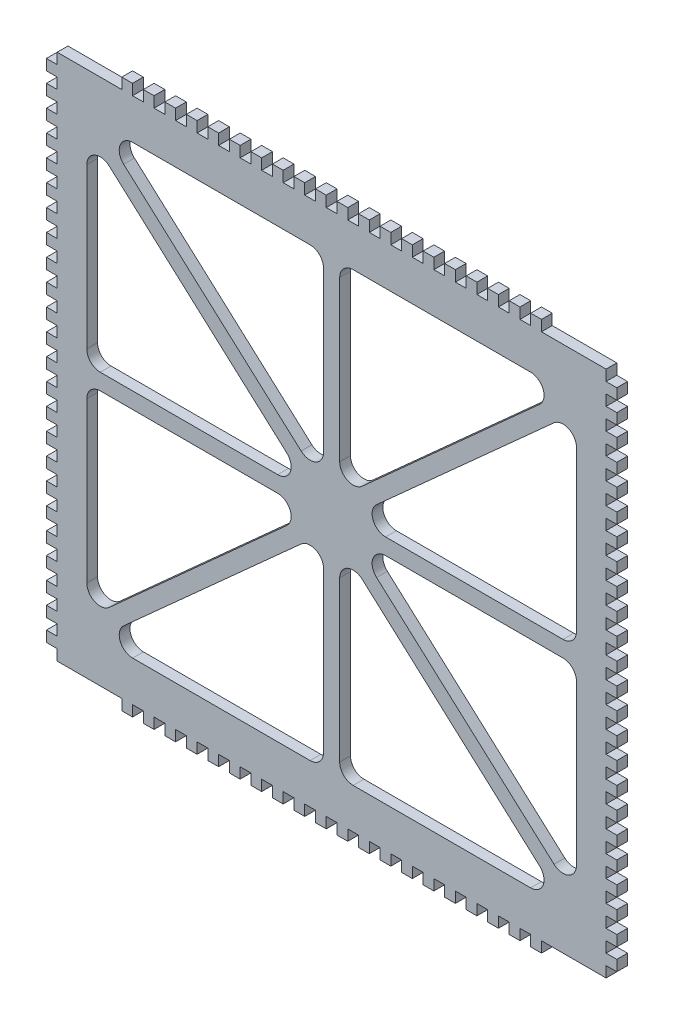
from build123d import *

# Parameters (mm, degrees)
SKETCH1_W           = 212
SKETCH1_H           = 196
BOSS_EXTRUDE1_DEPTH = 4
SKETCH2_W           = 4
SKETCH2_H           = 4
CUT_EXTRUDE1_DEPTH  = 4
SKETCH4_W           = 4
SKETCH4_H           = 4
BOSS_EXTRUDE2_DEPTH = 4


with BuildPart() as part:
    # Sketch1 → Boss-Extrude1 (new body)
    with BuildSketch(Plane.XY):
        Rectangle(SKETCH1_W, SKETCH1_H)
        with BuildLine():
            Line((-73.951477371, 83), (-8, 83))
            ThreePointArc((-8, 83), (-4.464466094, 81.535533906), (-3, 78))
            Line((-3, 78), (-3, 18.682929977))
            ThreePointArc((-3, 18.682929977), (-5.965055791, 14.115764328), (-11.343600827, 14.965359062))
            Line((-11.343600827, 14.965359062), (-77.295078198, 74.282429085))
            ThreePointArc((-77.295078198, 74.282429085), (-78.619874021, 79.790550952), (-73.951477371, 83))
        make_face(mode=Mode.SUBTRACT)
        with BuildLine():
            Line((-82.656399173, 71.034640938), (-16.704921802, 11.717570915))
            ThreePointArc((-16.704921802, 11.717570915), (-15.380125979, 6.209449048), (-20.048522629, 3))
            Line((-20.048522629, 3), (-86, 3))
            ThreePointArc((-86, 3), (-89.535533906, 4.464466094), (-91, 8))
            Line((-91, 8), (-91, 67.317070023))
            ThreePointArc((-91, 67.317070023), (-88.034944209, 71.884235672), (-82.656399173, 71.034640938))
        make_face(mode=Mode.SUBTRACT)
        with BuildLine():
            Line((8, 83), (73.951477371, 83))
            ThreePointArc((73.951477371, 83), (78.619874021, 79.790550952), (77.295078198, 74.282429085))
            Line((77.295078198, 74.282429085), (11.343600827, 14.965359062))
            ThreePointArc((11.343600827, 14.965359062), (5.965055791, 14.115764328), (3, 18.682929977))
            Line((3, 18.682929977), (3, 78))
            ThreePointArc((3, 78), (4.464466094, 81.535533906), (8, 83))
        make_face(mode=Mode.SUBTRACT)
        with BuildLine():
            Line((82.656399173, 71.034640938), (16.704921802, 11.717570915))
            ThreePointArc((16.704921802, 11.717570915), (15.380125979, 6.209449048), (20.048522629, 3))
            Line((20.048522629, 3), (86, 3))
            ThreePointArc((86, 3), (89.535533906, 4.464466094), (91, 8))
            Line((91, 8), (91, 67.317070023))
            ThreePointArc((91, 67.317070023), (88.034944209, 71.884235672), (82.656399173, 71.034640938))
        make_face(mode=Mode.SUBTRACT)
        with BuildLine():
            Line((-91, -8), (-91, -67.317070023))
            ThreePointArc((-91, -67.317070023), (-88.034944209, -71.884235672), (-82.656399173, -71.034640938))
            Line((-82.656399173, -71.034640938), (-16.704921802, -11.717570915))
            ThreePointArc((-16.704921802, -11.717570915), (-15.380125979, -6.209449048), (-20.048522629, -3))
            Line((-20.048522629, -3), (-86, -3))
            ThreePointArc((-86, -3), (-89.535533906, -4.464466094), (-91, -8))
        make_face(mode=Mode.SUBTRACT)
        with BuildLine():
            Line((91, -8), (91, -67.317070023))
            ThreePointArc((91, -67.317070023), (88.034944209, -71.884235672), (82.656399173, -71.034640938))
            Line((82.656399173, -71.034640938), (16.704921802, -11.717570915))
            ThreePointArc((16.704921802, -11.717570915), (15.380125979, -6.209449048), (20.048522629, -3))
            Line((20.048522629, -3), (86, -3))
            ThreePointArc((86, -3), (89.535533906, -4.464466094), (91, -8))
        make_face(mode=Mode.SUBTRACT)
        with BuildLine():
            Line((11.343600827, -14.965359062), (77.295078198, -74.282429085))
            ThreePointArc((77.295078198, -74.282429085), (78.619874021, -79.790550952), (73.951477371, -83))
            Line((73.951477371, -83), (8, -83))
            ThreePointArc((8, -83), (4.464466094, -81.535533906), (3, -78))
            Line((3, -78), (3, -18.682929977))
            ThreePointArc((3, -18.682929977), (5.965055791, -14.115764328), (11.343600827, -14.965359062))
        make_face(mode=Mode.SUBTRACT)
        with BuildLine():
            Line((-3, -18.682929977), (-3, -78))
            ThreePointArc((-3, -78), (-4.464466094, -81.535533906), (-8, -83))
            Line((-8, -83), (-73.951477371, -83))
            ThreePointArc((-73.951477371, -83), (-78.619874021, -79.790550952), (-77.295078198, -74.282429085))
            Line((-77.295078198, -74.282429085), (-11.343600827, -14.965359062))
            ThreePointArc((-11.343600827, -14.965359062), (-5.965055791, -14.115764328), (-3, -18.682929977))
        make_face(mode=Mode.SUBTRACT)
    extrude(amount=BOSS_EXTRUDE1_DEPTH)

    # Sketch2 → Cut-Extrude1 (cut)
    with BuildSketch(Plane.XY.offset(4)):
        with Locations((-104, -48)):
            Rectangle(SKETCH2_W, SKETCH2_H)
        with Locations((-104, 88)):
            Rectangle(SKETCH2_W, SKETCH2_H)
        with Locations((-104, 80)):
            Rectangle(SKETCH2_W, SKETCH2_H)
        with Locations((-104, 72)):
            Rectangle(SKETCH2_W, SKETCH2_H)
        with Locations((-104, 64)):
            Rectangle(SKETCH2_W, SKETCH2_H)
        with Locations((-104, 56)):
            Rectangle(SKETCH2_W, SKETCH2_H)
        with Locations((-104, 48)):
            Rectangle(SKETCH2_W, SKETCH2_H)
        with Locations((-104, 40)):
            Rectangle(SKETCH2_W, SKETCH2_H)
        with Locations((-104, 32)):
            Rectangle(SKETCH2_W, SKETCH2_H)
        with Locations((-104, 24)):
            Rectangle(SKETCH2_W, SKETCH2_H)
        with Locations((-104, 16)):
            Rectangle(SKETCH2_W, SKETCH2_H)
        with Locations((-104, 8)):
            Rectangle(SKETCH2_W, SKETCH2_H)
        with Locations((-104, 0)):
            Rectangle(SKETCH2_W, SKETCH2_H)
        with Locations((-104, -8)):
            Rectangle(SKETCH2_W, SKETCH2_H)
        with Locations((-104, -16)):
            Rectangle(SKETCH2_W, SKETCH2_H)
        with Locations((-104, -24)):
            Rectangle(SKETCH2_W, SKETCH2_H)
        with Locations((-104, -32)):
            Rectangle(SKETCH2_W, SKETCH2_H)
        with Locations((-104, -40)):
            Rectangle(SKETCH2_W, SKETCH2_H)
        with Locations((104, -96)):
            Rectangle(SKETCH2_W, SKETCH2_H)
        with Locations((104, -88)):
            Rectangle(SKETCH2_W, SKETCH2_H)
        with Locations((104, -80)):
            Rectangle(SKETCH2_W, SKETCH2_H)
        with Locations((104, -72)):
            Rectangle(SKETCH2_W, SKETCH2_H)
        with Locations((104, -64)):
            Rectangle(SKETCH2_W, SKETCH2_H)
        with Locations((104, -56)):
            Rectangle(SKETCH2_W, SKETCH2_H)
        with Locations((104, -48)):
            Rectangle(SKETCH2_W, SKETCH2_H)
        with Locations((104, 96)):
            Rectangle(SKETCH2_W, SKETCH2_H)
        with Locations((-104, 96)):
            Rectangle(SKETCH2_W, SKETCH2_H)
        with Locations((104, -40)):
            Rectangle(SKETCH2_W, SKETCH2_H)
        with Locations((104, -32)):
            Rectangle(SKETCH2_W, SKETCH2_H)
        with Locations((104, -24)):
            Rectangle(SKETCH2_W, SKETCH2_H)
        with Locations((104, -16)):
            Rectangle(SKETCH2_W, SKETCH2_H)
        with Locations((104, -8)):
            Rectangle(SKETCH2_W, SKETCH2_H)
        with Locations((104, 0)):
            Rectangle(SKETCH2_W, SKETCH2_H)
        with Locations((104, 8)):
            Rectangle(SKETCH2_W, SKETCH2_H)
        with Locations((104, 16)):
            Rectangle(SKETCH2_W, SKETCH2_H)
        with Locations((104, 24)):
            Rectangle(SKETCH2_W, SKETCH2_H)
        with Locations((104, 32)):
            Rectangle(SKETCH2_W, SKETCH2_H)
        with Locations((104, 40)):
            Rectangle(SKETCH2_W, SKETCH2_H)
        with Locations((-104, -56)):
            Rectangle(SKETCH2_W, SKETCH2_H)
        with Locations((104, 48)):
            Rectangle(SKETCH2_W, SKETCH2_H)
        with Locations((104, 56)):
            Rectangle(SKETCH2_W, SKETCH2_H)
        with Locations((-104, -64)):
            Rectangle(SKETCH2_W, SKETCH2_H)
        with Locations((-104, -72)):
            Rectangle(SKETCH2_W, SKETCH2_H)
        with Locations((-104, -80)):
            Rectangle(SKETCH2_W, SKETCH2_H)
        with Locations((-104, -88)):
            Rectangle(SKETCH2_W, SKETCH2_H)
        with Locations((-104, -96)):
            Rectangle(SKETCH2_W, SKETCH2_H)
        with Locations((104, 64)):
            Rectangle(SKETCH2_W, SKETCH2_H)
        with Locations((104, 72)):
            Rectangle(SKETCH2_W, SKETCH2_H)
        with Locations((104, 80)):
            Rectangle(SKETCH2_W, SKETCH2_H)
        with Locations((104, 88)):
            Rectangle(SKETCH2_W, SKETCH2_H)
    extrude(amount=-CUT_EXTRUDE1_DEPTH, mode=Mode.SUBTRACT)

    # Sketch4 → Boss-Extrude2 (add)
    with BuildSketch(Plane(origin=(0, 0, 0), x_dir=(-1, 0, 0), z_dir=(0, 0, -1))):
        with Locations((-12, 100)):
            Rectangle(SKETCH4_W, SKETCH4_H)
        with Locations((-4, 100)):
            Rectangle(SKETCH4_W, SKETCH4_H)
        with Locations((-20, 100)):
            Rectangle(SKETCH4_W, SKETCH4_H)
        with Locations((-28, 100)):
            Rectangle(SKETCH4_W, SKETCH4_H)
        with Locations((-36, 100)):
            Rectangle(SKETCH4_W, SKETCH4_H)
        with Locations((-44, 100)):
            Rectangle(SKETCH4_W, SKETCH4_H)
        with Locations((-52, 100)):
            Rectangle(SKETCH4_W, SKETCH4_H)
        with Locations((-60, 100)):
            Rectangle(SKETCH4_W, SKETCH4_H)
        with Locations((-68, 100)):
            Rectangle(SKETCH4_W, SKETCH4_H)
        with Locations((-76, 100)):
            Rectangle(SKETCH4_W, SKETCH4_H)
        with Locations((76, 100)):
            Rectangle(SKETCH4_W, SKETCH4_H)
        with Locations((68, 100)):
            Rectangle(SKETCH4_W, SKETCH4_H)
        with Locations((60, 100)):
            Rectangle(SKETCH4_W, SKETCH4_H)
        with Locations((52, 100)):
            Rectangle(SKETCH4_W, SKETCH4_H)
        with Locations((44, 100)):
            Rectangle(SKETCH4_W, SKETCH4_H)
        with Locations((36, 100)):
            Rectangle(SKETCH4_W, SKETCH4_H)
        with Locations((28, 100)):
            Rectangle(SKETCH4_W, SKETCH4_H)
        with Locations((20, 100)):
            Rectangle(SKETCH4_W, SKETCH4_H)
        with Locations((12, 100)):
            Rectangle(SKETCH4_W, SKETCH4_H)
        with Locations((4, 100)):
            Rectangle(SKETCH4_W, SKETCH4_H)
        with Locations((12, -100)):
            Rectangle(SKETCH4_W, SKETCH4_H)
        with Locations((4, -100)):
            Rectangle(SKETCH4_W, SKETCH4_H)
        with Locations((20, -100)):
            Rectangle(SKETCH4_W, SKETCH4_H)
        with Locations((28, -100)):
            Rectangle(SKETCH4_W, SKETCH4_H)
        with Locations((36, -100)):
            Rectangle(SKETCH4_W, SKETCH4_H)
        with Locations((44, -100)):
            Rectangle(SKETCH4_W, SKETCH4_H)
        with Locations((52, -100)):
            Rectangle(SKETCH4_W, SKETCH4_H)
        with Locations((60, -100)):
            Rectangle(SKETCH4_W, SKETCH4_H)
        with Locations((68, -100)):
            Rectangle(SKETCH4_W, SKETCH4_H)
        with Locations((76, -100)):
            Rectangle(SKETCH4_W, SKETCH4_H)
        with Locations((-76, -100)):
            Rectangle(SKETCH4_W, SKETCH4_H)
        with Locations((-68, -100)):
            Rectangle(SKETCH4_W, SKETCH4_H)
        with Locations((-60, -100)):
            Rectangle(SKETCH4_W, SKETCH4_H)
        with Locations((-52, -100)):
            Rectangle(SKETCH4_W, SKETCH4_H)
        with Locations((-44, -100)):
            Rectangle(SKETCH4_W, SKETCH4_H)
        with Locations((-36, -100)):
            Rectangle(SKETCH4_W, SKETCH4_H)
        with Locations((-28, -100)):
            Rectangle(SKETCH4_W, SKETCH4_H)
        with Locations((-20, -100)):
            Rectangle(SKETCH4_W, SKETCH4_H)
        with Locations((-12, -100)):
            Rectangle(SKETCH4_W, SKETCH4_H)
        with Locations((-4, -100)):
            Rectangle(SKETCH4_W, SKETCH4_H)
    extrude(amount=-BOSS_EXTRUDE2_DEPTH)


solid = part.part
